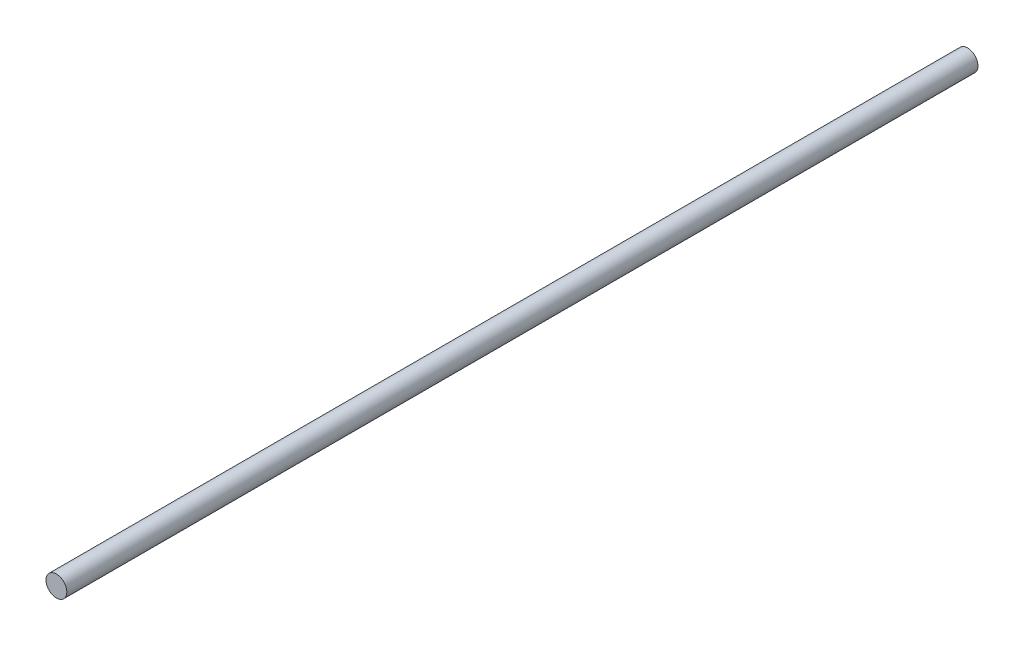
from build123d import *

# Parameters (mm, degrees)
ESQUISSE1_R        = 4
BOSS_EXTRU_1_DEPTH = 350


with BuildPart() as part:
    # Esquisse1 → Boss.-Extru.1 (new body)
    with BuildSketch(Plane.XY):
        Circle(ESQUISSE1_R)
    extrude(amount=BOSS_EXTRU_1_DEPTH)


solid = part.part
